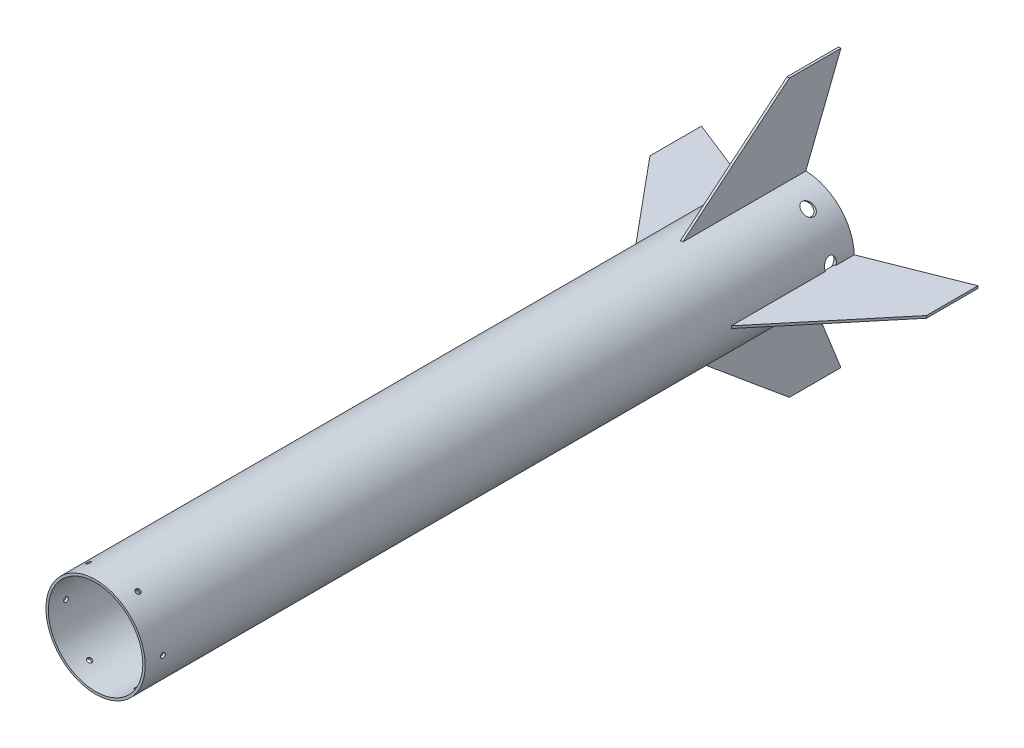
from build123d import *

# Parameters (mm, degrees)
SKETCH1_R               = 42
SKETCH1_R_2             = 40
BOSS_EXTRUDE1_DEPTH     = 600
CUT_EXTRUDE1_REACH      = 609.728
CUT_EXTRUDE1_END_RADIUS = 40
SKETCH2_R               = 2
CIRPATTERN1_COUNT       = 6
CUT_EXTRUDE2_REACH      = 609.306
SKETCH4_R               = 5
CIRPATTERN2_COUNT       = 7
BOSS_EXTRUDE6_DEPTH     = 1
CIRPATTERN3_COUNT       = 4


with BuildPart() as part:
    # Sketch1 → Boss-Extrude1 (new body)
    with BuildSketch(Plane.XY):
        Circle(SKETCH1_R)
        Circle(SKETCH1_R_2, mode=Mode.SUBTRACT)
    extrude(amount=BOSS_EXTRUDE1_DEPTH)

    # Cut-Extrude1: up to this cylinder (the profile starts outside it)
    cut_extrude1_end = Plane(origin=(0, 0, 585), z_dir=(0, 0, -1)) * Cylinder(CUT_EXTRUDE1_END_RADIUS, 1300.456, mode=Mode.PRIVATE)
    # Sketch2 → Cut-Extrude1 (cut, up to the surface)
    with BuildSketch(Plane(origin=(45, 0, 0), x_dir=(0, 0, -1), z_dir=(1, 0, 0)), mode=Mode.PRIVATE) as cut_extrude1_sk1:
        with Locations((-585, 0)):
            Circle(SKETCH2_R)
    cut_extrude1_tool1 = extrude(cut_extrude1_sk1.sketch, amount=-CUT_EXTRUDE1_REACH, mode=Mode.PRIVATE) - cut_extrude1_end
    cut_extrude1 = cut_extrude1_tool1.solids().sort_by_distance((45, 0, 585))[0]
    add(cut_extrude1, mode=Mode.SUBTRACT)

    # CirPattern1: Cut-Extrude1 ×6 about axis
    cirpattern1_axis = Axis((0, 0, 600), (0, 0, -1))
    for i in range(1, CIRPATTERN1_COUNT):
        add(cut_extrude1.rotate(cirpattern1_axis, i * 360 / CIRPATTERN1_COUNT), mode=Mode.SUBTRACT)

    # Sketch4 → Cut-Extrude2 (cut, up to next)
    with BuildSketch(Plane.ZY.offset(42), mode=Mode.PRIVATE) as cut_extrude2_sk1:
        with Locations((20, -21.573561533)):
            Circle(SKETCH4_R)
    cut_extrude2_tool1 = extrude(cut_extrude2_sk1.sketch, amount=-CUT_EXTRUDE2_REACH, mode=Mode.PRIVATE) & part.part
    cut_extrude2 = cut_extrude2_tool1.solids().sort_by_distance((-42, -21.573562, 20))[0]
    add(cut_extrude2, mode=Mode.SUBTRACT)

    # CirPattern2: Cut-Extrude2 ×7 about axis
    cirpattern2_axis = Axis((0, 0, 600), (0, 0, -1))
    for i in range(1, CIRPATTERN2_COUNT):
        add(cut_extrude2.rotate(cirpattern2_axis, i * 360 / CIRPATTERN2_COUNT), mode=Mode.SUBTRACT)


with BuildPart() as body_2:
    # Sketch13 → Boss-Extrude6 (new, symmetric)
    with BuildSketch(Plane.ZY):
        Polygon((104, 42), (13.9, 117), (-29.7, 117), (0, 42), (0, 41), (104, 41), align=None)
    boss_extrude6 = extrude(amount=BOSS_EXTRUDE6_DEPTH, both=True)


with BuildPart() as part_1:
    add(part.part)

    # CirPattern3: Boss-Extrude6 ×4 about axis
    cirpattern3_axis = Axis((0, 0, 0), (0, 0, 1))
    for i in range(1, CIRPATTERN3_COUNT):
        add(boss_extrude6.rotate(cirpattern3_axis, i * 360 / CIRPATTERN3_COUNT))


solid = Compound([body_2.part, part_1.part])
